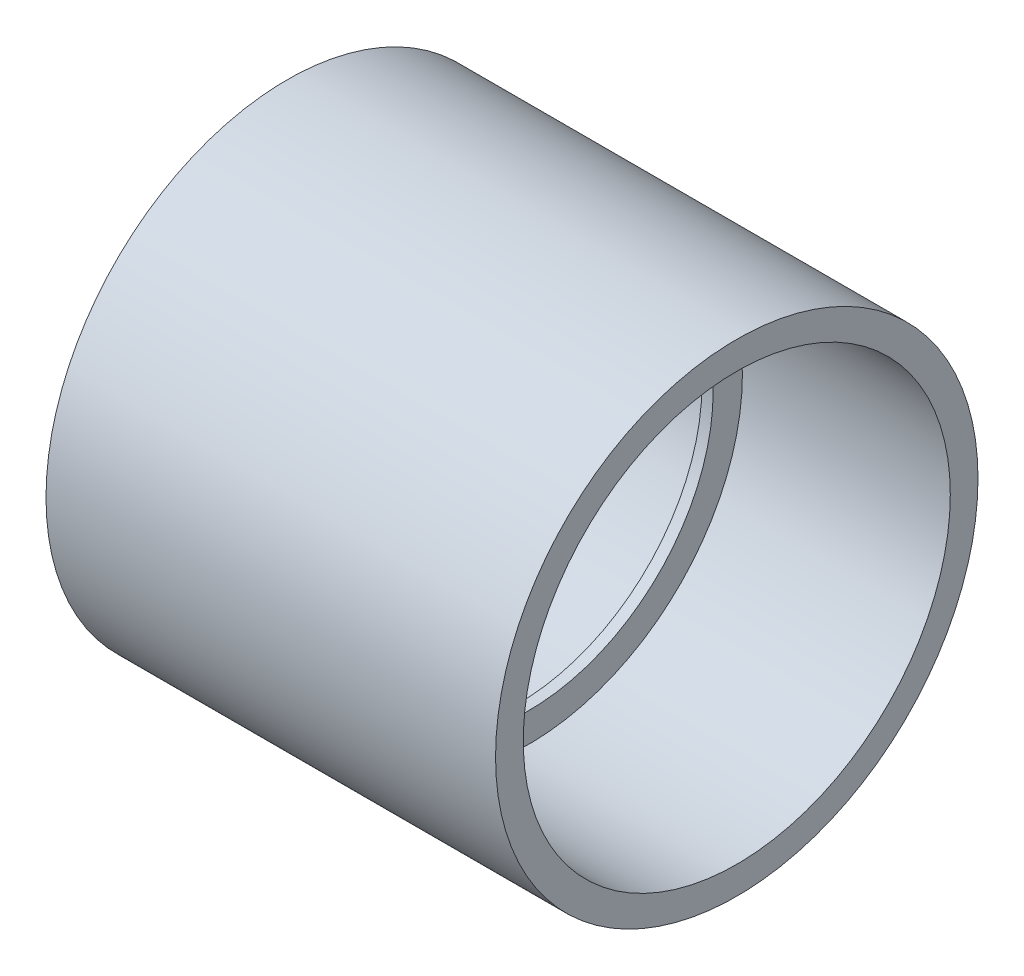
from build123d import *

# Parameters (mm, degrees)
SKETCH1_R           = 34.0741
SKETCH1_R_2         = 30.1625
BOSS_EXTRUDE1_DEPTH = 63.5
BOSS_EXTRUDE2_START = -30.95625
SKETCH2_R           = 30.1625
SKETCH2_R_2         = 26.035
BOSS_EXTRUDE2_DEPTH = 1.5875


with BuildPart() as part:
    # Sketch1 → Boss-Extrude1 (new body)
    with BuildSketch(Plane(origin=(0, 0, 0), x_dir=(0, 0, -1), z_dir=(1, 0, 0))):
        Circle(SKETCH1_R)
        Circle(SKETCH1_R_2, mode=Mode.SUBTRACT)
    extrude(amount=BOSS_EXTRUDE1_DEPTH)

    # Sketch2 → Boss-Extrude2 (add)
    with BuildSketch(Plane(origin=(63.5, 0, 0), x_dir=(0, 0, -1), z_dir=(1, 0, 0)).offset(BOSS_EXTRUDE2_START)):
        Circle(SKETCH2_R)
        Circle(SKETCH2_R_2, mode=Mode.SUBTRACT)
    extrude(amount=BOSS_EXTRUDE2_DEPTH)


solid = part.part
